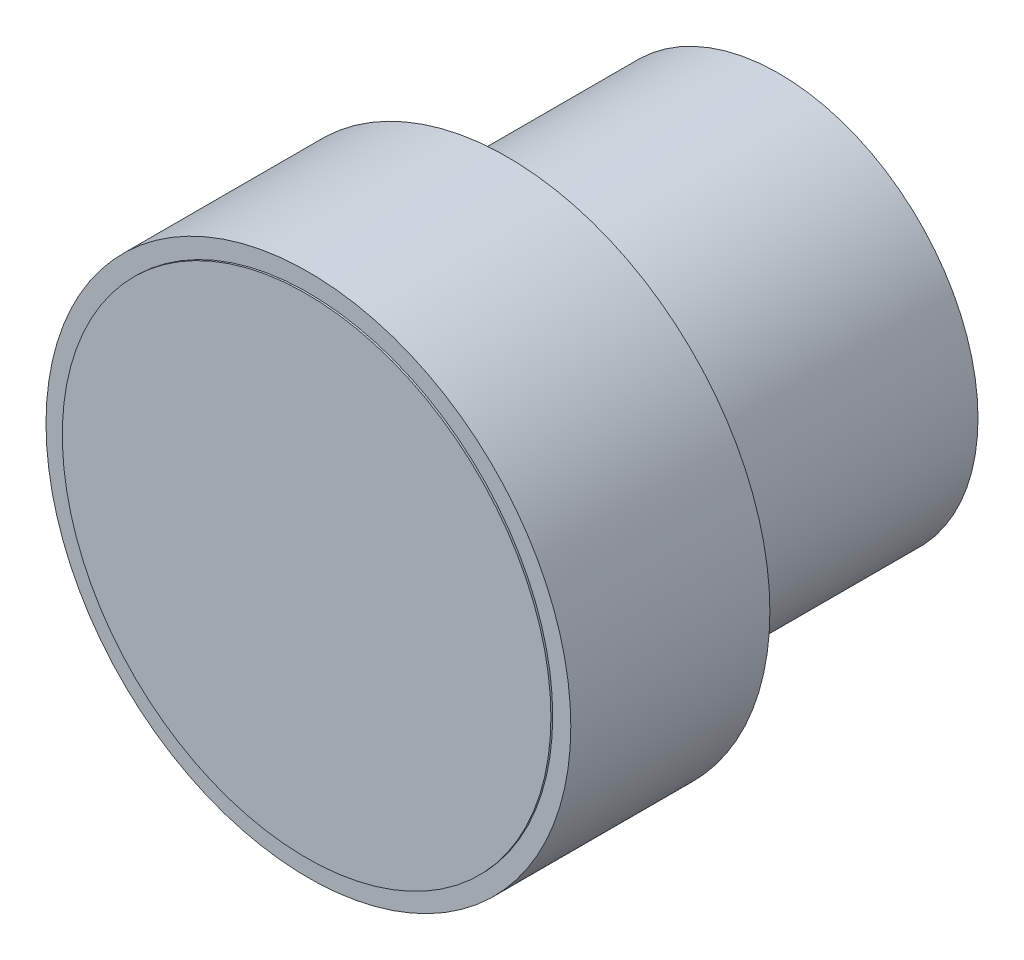
from build123d import *

# Parameters (mm, degrees)
SKETCH_1_R      = 11
EXTRUDE_1_DEPTH = 15
SKETCH_2_R      = 14.5
EXTRUDE_2_DEPTH = 11
SKETCH_3_R      = 13.5
EXTRUDE_3_DEPTH = 0.1


with BuildPart() as part:
    # 草图1 → 凸台-拉伸1 (new body)
    with BuildSketch(Plane.XY):
        Circle(SKETCH_1_R)
    extrude(amount=EXTRUDE_1_DEPTH)

    # 草图2 → 凸台-拉伸2 (add)
    with BuildSketch(Plane.XY.offset(15)):
        Circle(SKETCH_2_R)
    extrude(amount=EXTRUDE_2_DEPTH)

    # 草图3 → 凸台-拉伸3 (add)
    with BuildSketch(Plane.XY.offset(26)):
        Circle(SKETCH_3_R)
    extrude(amount=EXTRUDE_3_DEPTH)


solid = part.part
